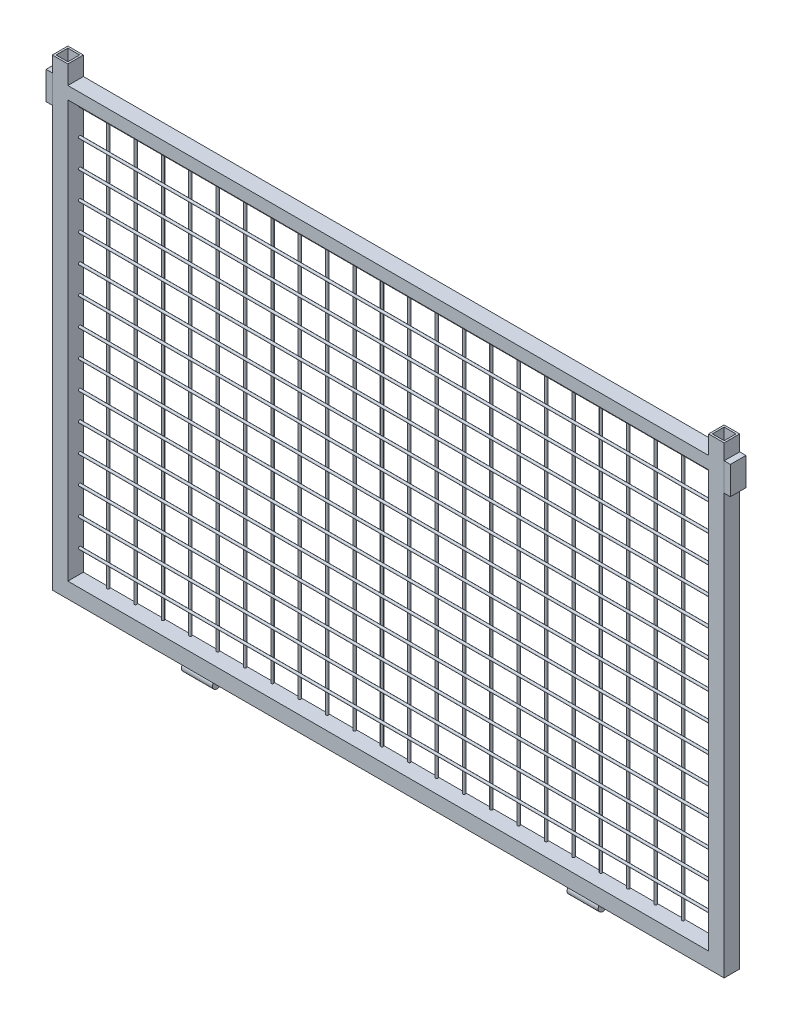
from build123d import *

# Parameters (mm, degrees)
SCHIZZO1_W                      = 25
SCHIZZO1_H                      = 25
SCHIZZO1_W_2                    = 19
SCHIZZO1_H_2                    = 19
ESTRUSIONE_ESTRUSIONE1_DEPTH    = 745
ESTRUSIONE_ESTRUSIONE1_2_DEPTH  = 745
SCHIZZO2_W                      = 25
SCHIZZO2_H                      = 25
SCHIZZO2_W_2                    = 19
SCHIZZO2_H_2                    = 19
ESTRUSIONE_ESTRUSIONE2_DEPTH    = 1030
ESTRUSIONE_ESTRUSIONE2_2_DEPTH  = 1030
SCHIZZO4_R                      = 7.5
ESTRUSIONE_ESTRUSIONE3_DEPTH    = 50
SCHIZZO5_W                      = 25
SCHIZZO5_H                      = 45
ESTRUSIONE_ESTRUSIONE4_DEPTH    = 10
SCHIZZO6_R                      = 2
ESTRUSIONE_ESTRUSIONE5_DEPTH    = 698
SCHIZZO7_R                      = 2
ESTRUSIONE_ESTRUSIONE7_DEPTH    = 1030
ESTRUSIONE_ESTRUSIONE7_2_DEPTH  = 1030
ESTRUSIONE_ESTRUSIONE7_3_DEPTH  = 1030
ESTRUSIONE_ESTRUSIONE7_4_DEPTH  = 1030
ESTRUSIONE_ESTRUSIONE7_5_DEPTH  = 1030
ESTRUSIONE_ESTRUSIONE7_6_DEPTH  = 1030
ESTRUSIONE_ESTRUSIONE7_7_DEPTH  = 1030
ESTRUSIONE_ESTRUSIONE7_8_DEPTH  = 1030
ESTRUSIONE_ESTRUSIONE7_9_DEPTH  = 1030
ESTRUSIONE_ESTRUSIONE7_10_DEPTH = 1030
ESTRUSIONE_ESTRUSIONE7_11_DEPTH = 1030
ESTRUSIONE_ESTRUSIONE7_12_DEPTH = 1030
ESTRUSIONE_ESTRUSIONE7_13_DEPTH = 1030
ESTRUSIONE_ESTRUSIONE7_14_DEPTH = 1030
ESTRUSIONE_ESTRUSIONE7_15_DEPTH = 1030
SCHIZZO8_W                      = 1030
SCHIZZO8_H                      = 20
TAGLIO_ESTRUSIONE1_DEPTH        = 39
SCHIZZO9_W                      = 25
SCHIZZO9_H                      = 25
ESTRUSIONE_ESTRUSIONE8_DEPTH    = 1030
SCHIZZO10_W                     = 1030
SCHIZZO10_H                     = 10
TAGLIO_ESTRUSIONE2_DEPTH        = 26


with BuildPart() as part:
    # Schizzo1 → Estrusione-Estrusione1 (new body)
    with BuildSketch(Plane(origin=(0, 0, 0), x_dir=(1, 0, 0), z_dir=(0, 1, 0))):
        with Locations((-527.5, 0)):
            Rectangle(SCHIZZO1_W, SCHIZZO1_H)
        with Locations((-527.5, 0)):
            Rectangle(SCHIZZO1_W_2, SCHIZZO1_H_2, mode=Mode.SUBTRACT)
    extrude(amount=ESTRUSIONE_ESTRUSIONE1_DEPTH)



with BuildPart() as body_2:
    # Schizzo1 → Estrusione-Estrusione1 2 (new body)
    with BuildSketch(Plane(origin=(0, 0, 0), x_dir=(1, 0, 0), z_dir=(0, 1, 0))):
        with Locations((527.5, 0)):
            Rectangle(SCHIZZO1_W, SCHIZZO1_H)
        with Locations((527.5, 0)):
            Rectangle(SCHIZZO1_W_2, SCHIZZO1_H_2, mode=Mode.SUBTRACT)
    extrude(amount=ESTRUSIONE_ESTRUSIONE1_2_DEPTH)


with BuildPart() as body_3:
    # Schizzo2 → Estrusione-Estrusione2 (new body)
    with BuildSketch(Plane(origin=(-515, 0, 0), x_dir=(0, 0, -1), z_dir=(1, 0, 0))):
        with Locations((0, 12.5)):
            Rectangle(SCHIZZO2_W, SCHIZZO2_H)
        with Locations((0, 12.5)):
            Rectangle(SCHIZZO2_W_2, SCHIZZO2_H_2, mode=Mode.SUBTRACT)
    extrude(amount=ESTRUSIONE_ESTRUSIONE2_DEPTH)



with BuildPart() as body_4:
    # Schizzo2 → Estrusione-Estrusione2 2 (new body)
    with BuildSketch(Plane(origin=(-515, 0, 0), x_dir=(0, 0, -1), z_dir=(1, 0, 0))):
        with Locations((0, 732.5)):
            Rectangle(SCHIZZO2_W, SCHIZZO2_H)
        with Locations((0, 732.5)):
            Rectangle(SCHIZZO2_W_2, SCHIZZO2_H_2, mode=Mode.SUBTRACT)
    extrude(amount=ESTRUSIONE_ESTRUSIONE2_2_DEPTH)


with BuildPart() as body_5:
    # Schizzo4 → Estrusione-Estrusione3 (new body)
    with BuildSketch(Plane(origin=(335, 0, 0), x_dir=(0, 0, -1), z_dir=(1, 0, 0))):
        with Locations((-2.5, -7.5)):
            Circle(SCHIZZO4_R)
    extrude(amount=-ESTRUSIONE_ESTRUSIONE3_DEPTH)


with BuildPart() as body_6:
    # Specchia1: mirrored copy
    add(body_5.part.mirror(Plane(origin=(0, 0, 0), x_dir=(0, 0, 1), z_dir=(1, 0, 0))))


with BuildPart() as body_7:
    # Schizzo5 → Estrusione-Estrusione4 (new body)
    with BuildSketch(Plane(origin=(540, 0, 0), x_dir=(0, 0, -1), z_dir=(1, 0, 0))):
        with Locations((0, 697.5)):
            Rectangle(SCHIZZO5_W, SCHIZZO5_H)
    extrude(amount=ESTRUSIONE_ESTRUSIONE4_DEPTH)


with BuildPart() as body_8:
    # Specchia2: mirrored copy
    add(body_7.part.mirror(Plane(origin=(0, 0, 0), x_dir=(0, 0, 1), z_dir=(1, 0, 0))))


with BuildPart() as body_3_1:
    add(body_3.part)

    add(body_4.part)  # Estrusione-Estrusione5 merges body 4
    # Schizzo6 → Estrusione-Estrusione5 (add)
    with BuildSketch(Plane(origin=(0, 25, 0), x_dir=(1, 0, 0), z_dir=(0, 1, 0))):
        with Locations((-473, 10.5)):
            Circle(SCHIZZO6_R)
        with Locations((-429, 10.5)):
            Circle(SCHIZZO6_R)
        with Locations((-385, 10.5)):
            Circle(SCHIZZO6_R)
        with Locations((-341, 10.5)):
            Circle(SCHIZZO6_R)
        with Locations((-297, 10.5)):
            Circle(SCHIZZO6_R)
        with Locations((-253, 10.5)):
            Circle(SCHIZZO6_R)
        with Locations((-209, 10.5)):
            Circle(SCHIZZO6_R)
        with Locations((-165, 10.5)):
            Circle(SCHIZZO6_R)
        with Locations((-121, 10.5)):
            Circle(SCHIZZO6_R)
        with Locations((-77, 10.5)):
            Circle(SCHIZZO6_R)
        with Locations((-33, 10.5)):
            Circle(SCHIZZO6_R)
        with Locations((11, 10.5)):
            Circle(SCHIZZO6_R)
        with Locations((55, 10.5)):
            Circle(SCHIZZO6_R)
        with Locations((99, 10.5)):
            Circle(SCHIZZO6_R)
        with Locations((143, 10.5)):
            Circle(SCHIZZO6_R)
        with Locations((187, 10.5)):
            Circle(SCHIZZO6_R)
        with Locations((231, 10.5)):
            Circle(SCHIZZO6_R)
        with Locations((275, 10.5)):
            Circle(SCHIZZO6_R)
        with Locations((319, 10.5)):
            Circle(SCHIZZO6_R)
        with Locations((363, 10.5)):
            Circle(SCHIZZO6_R)
        with Locations((407, 10.5)):
            Circle(SCHIZZO6_R)
        with Locations((451, 10.5)):
            Circle(SCHIZZO6_R)
        with Locations((495, 10.5)):
            Circle(SCHIZZO6_R)
    extrude(amount=ESTRUSIONE_ESTRUSIONE5_DEPTH)

    # Schizzo8 → Taglio-Estrusione1 (cut)
    with BuildSketch(Plane(origin=(0, 0, -12.5), x_dir=(-1, 0, 0), z_dir=(0, 0, -1))):
        with Locations((0, 735)):
            Rectangle(SCHIZZO8_W, SCHIZZO8_H)
    extrude(amount=-TAGLIO_ESTRUSIONE1_DEPTH, mode=Mode.SUBTRACT)


with BuildPart() as body_8_2:
    # Schizzo7 → Estrusione-Estrusione7 (new body)
    with BuildSketch(Plane(origin=(-515, 0, 0), x_dir=(0, 0, -1), z_dir=(1, 0, 0))):
        with Locations((6.5, 678)):
            Circle(SCHIZZO7_R)
    extrude(amount=ESTRUSIONE_ESTRUSIONE7_DEPTH)


with BuildPart() as body_9:
    # Schizzo7 → Estrusione-Estrusione7 2 (new body)
    with BuildSketch(Plane(origin=(-515, 0, 0), x_dir=(0, 0, -1), z_dir=(1, 0, 0))):
        with Locations((6.5, 634)):
            Circle(SCHIZZO7_R)
    extrude(amount=ESTRUSIONE_ESTRUSIONE7_2_DEPTH)


with BuildPart() as body_10:
    # Schizzo7 → Estrusione-Estrusione7 3 (new body)
    with BuildSketch(Plane(origin=(-515, 0, 0), x_dir=(0, 0, -1), z_dir=(1, 0, 0))):
        with Locations((6.5, 590)):
            Circle(SCHIZZO7_R)
    extrude(amount=ESTRUSIONE_ESTRUSIONE7_3_DEPTH)


with BuildPart() as body_11:
    # Schizzo7 → Estrusione-Estrusione7 4 (new body)
    with BuildSketch(Plane(origin=(-515, 0, 0), x_dir=(0, 0, -1), z_dir=(1, 0, 0))):
        with Locations((6.5, 546)):
            Circle(SCHIZZO7_R)
    extrude(amount=ESTRUSIONE_ESTRUSIONE7_4_DEPTH)


with BuildPart() as body_12:
    # Schizzo7 → Estrusione-Estrusione7 5 (new body)
    with BuildSketch(Plane(origin=(-515, 0, 0), x_dir=(0, 0, -1), z_dir=(1, 0, 0))):
        with Locations((6.5, 502)):
            Circle(SCHIZZO7_R)
    extrude(amount=ESTRUSIONE_ESTRUSIONE7_5_DEPTH)


with BuildPart() as body_13:
    # Schizzo7 → Estrusione-Estrusione7 6 (new body)
    with BuildSketch(Plane(origin=(-515, 0, 0), x_dir=(0, 0, -1), z_dir=(1, 0, 0))):
        with Locations((6.5, 458)):
            Circle(SCHIZZO7_R)
    extrude(amount=ESTRUSIONE_ESTRUSIONE7_6_DEPTH)


with BuildPart() as body_14:
    # Schizzo7 → Estrusione-Estrusione7 7 (new body)
    with BuildSketch(Plane(origin=(-515, 0, 0), x_dir=(0, 0, -1), z_dir=(1, 0, 0))):
        with Locations((6.5, 414)):
            Circle(SCHIZZO7_R)
    extrude(amount=ESTRUSIONE_ESTRUSIONE7_7_DEPTH)


with BuildPart() as body_15:
    # Schizzo7 → Estrusione-Estrusione7 8 (new body)
    with BuildSketch(Plane(origin=(-515, 0, 0), x_dir=(0, 0, -1), z_dir=(1, 0, 0))):
        with Locations((6.5, 370)):
            Circle(SCHIZZO7_R)
    extrude(amount=ESTRUSIONE_ESTRUSIONE7_8_DEPTH)


with BuildPart() as body_16:
    # Schizzo7 → Estrusione-Estrusione7 9 (new body)
    with BuildSketch(Plane(origin=(-515, 0, 0), x_dir=(0, 0, -1), z_dir=(1, 0, 0))):
        with Locations((6.5, 326)):
            Circle(SCHIZZO7_R)
    extrude(amount=ESTRUSIONE_ESTRUSIONE7_9_DEPTH)


with BuildPart() as body_17:
    # Schizzo7 → Estrusione-Estrusione7 10 (new body)
    with BuildSketch(Plane(origin=(-515, 0, 0), x_dir=(0, 0, -1), z_dir=(1, 0, 0))):
        with Locations((6.5, 282)):
            Circle(SCHIZZO7_R)
    extrude(amount=ESTRUSIONE_ESTRUSIONE7_10_DEPTH)


with BuildPart() as body_18:
    # Schizzo7 → Estrusione-Estrusione7 11 (new body)
    with BuildSketch(Plane(origin=(-515, 0, 0), x_dir=(0, 0, -1), z_dir=(1, 0, 0))):
        with Locations((6.5, 238)):
            Circle(SCHIZZO7_R)
    extrude(amount=ESTRUSIONE_ESTRUSIONE7_11_DEPTH)


with BuildPart() as body_19:
    # Schizzo7 → Estrusione-Estrusione7 12 (new body)
    with BuildSketch(Plane(origin=(-515, 0, 0), x_dir=(0, 0, -1), z_dir=(1, 0, 0))):
        with Locations((6.5, 194)):
            Circle(SCHIZZO7_R)
    extrude(amount=ESTRUSIONE_ESTRUSIONE7_12_DEPTH)


with BuildPart() as body_20:
    # Schizzo7 → Estrusione-Estrusione7 13 (new body)
    with BuildSketch(Plane(origin=(-515, 0, 0), x_dir=(0, 0, -1), z_dir=(1, 0, 0))):
        with Locations((6.5, 150)):
            Circle(SCHIZZO7_R)
    extrude(amount=ESTRUSIONE_ESTRUSIONE7_13_DEPTH)


with BuildPart() as body_21:
    # Schizzo7 → Estrusione-Estrusione7 14 (new body)
    with BuildSketch(Plane(origin=(-515, 0, 0), x_dir=(0, 0, -1), z_dir=(1, 0, 0))):
        with Locations((6.5, 106)):
            Circle(SCHIZZO7_R)
    extrude(amount=ESTRUSIONE_ESTRUSIONE7_14_DEPTH)


with BuildPart() as body_22:
    # Schizzo7 → Estrusione-Estrusione7 15 (new body)
    with BuildSketch(Plane(origin=(-515, 0, 0), x_dir=(0, 0, -1), z_dir=(1, 0, 0))):
        with Locations((6.5, 62)):
            Circle(SCHIZZO7_R)
    extrude(amount=ESTRUSIONE_ESTRUSIONE7_15_DEPTH)


with BuildPart() as part_1:
    add(part.part)

    add(body_2.part)  # Estrusione-Estrusione8 merges body 2

    add(body_3_1.part)  # Estrusione-Estrusione8 merges body 3
    # Schizzo9 → Estrusione-Estrusione8 (add)
    with BuildSketch(Plane.ZY.offset(-515)):
        with Locations((0, 707.5)):
            Rectangle(SCHIZZO9_W, SCHIZZO9_H)
    extrude(amount=ESTRUSIONE_ESTRUSIONE8_DEPTH)

    # Schizzo10 → Taglio-Estrusione2 (cut, through all)
    with BuildSketch(Plane.XY.offset(12.5)):
        with Locations((0, 720)):
            Rectangle(SCHIZZO10_W, SCHIZZO10_H)
    extrude(amount=-TAGLIO_ESTRUSIONE2_DEPTH, mode=Mode.SUBTRACT)


solid = Compound([body_5.part, body_6.part, body_7.part, body_8.part, body_8_2.part, body_9.part, body_10.part, body_11.part, body_12.part, body_13.part, body_14.part, body_15.part, body_16.part, body_17.part, body_18.part, body_19.part, body_20.part, body_21.part, body_22.part, part_1.part])
